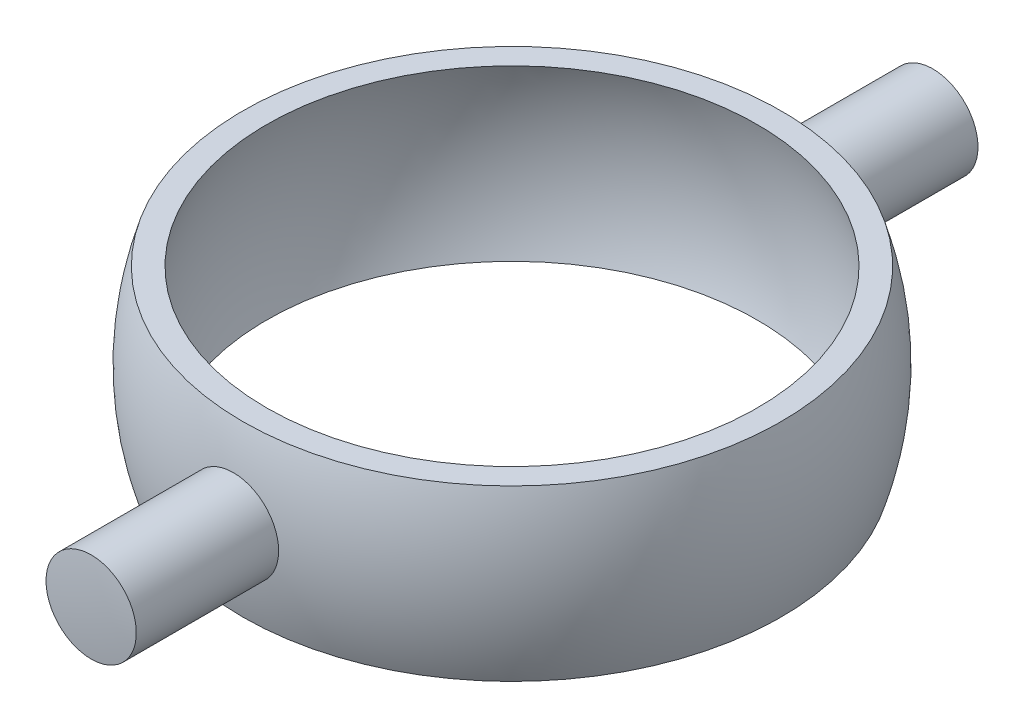
from build123d import *

# Parameters (mm, degrees)
SKETCH3_R           = 4
BOSS_EXTRUDE1_DEPTH = 12.822075


with BuildPart() as part:
    # Sketch1 → Revolve1 (revolve)
    with BuildSketch(Plane.XY):
        with BuildLine():
            Line((-23.848480035, 7.5), (-21.742814905, 7.5))
            ThreePointArc((-21.742814905, 7.5), (-23, 0), (-21.742814905, -7.5))
            Line((-21.742814905, -7.5), (-23.848480035, -7.5))
            ThreePointArc((-23.848480035, -7.5), (-25, 0), (-23.848480035, 7.5))
        make_face()
    revolve(axis=Axis((0, 8.20070368, 0), (0, -1, 0)))

    # Sketch3 → Boss-Extrude1 (add)
    with BuildSketch(Plane.XY.offset(37.5)):
        Circle(SKETCH3_R)
    boss_extrude1 = extrude(amount=-BOSS_EXTRUDE1_DEPTH)

    # Mirror1: Boss-Extrude1 across plane
    add(boss_extrude1.mirror(Plane.XY))

    # Sketch4 → Cut-Revolve1 (revolve, cut)
    with BuildSketch(Plane(origin=(0, 0, 0), x_dir=(0, 0, -1), z_dir=(1, 0, 0))):
        with BuildLine():
            Line((0, 40), (0, 37.5))
            ThreePointArc((0, 37.5), (-37.5, 0), (0, -37.5))
            Line((0, -37.5), (0, -40))
            ThreePointArc((0, -40), (-40, 0), (0, 40))
        make_face()
    revolve(axis=Axis((0, 37.5, 0), (0, -1, 0)), mode=Mode.SUBTRACT)


solid = part.part
